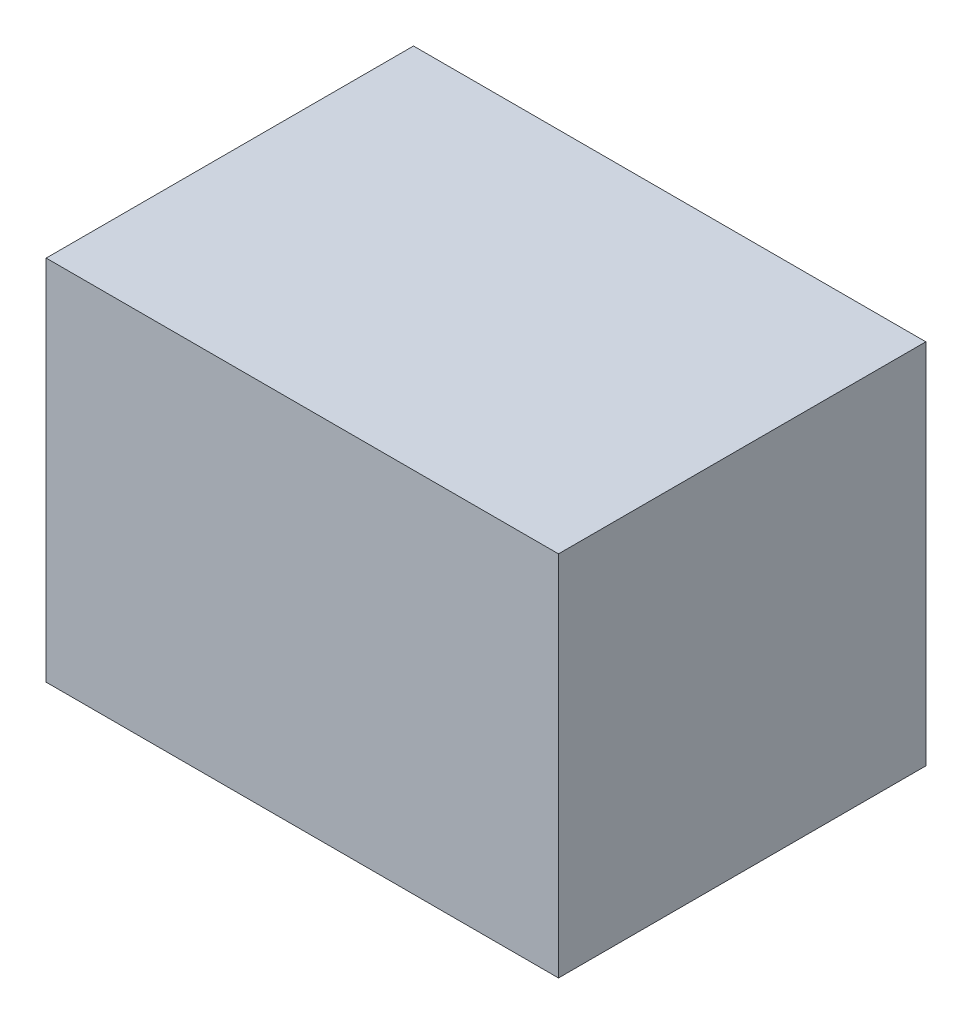
from build123d import *

# Parameters (mm, degrees)
SKETCH1_W           = 53
SKETCH1_H           = 38
BOSS_EXTRUDE1_DEPTH = 38


with BuildPart() as part:
    # Sketch1 → Boss-Extrude1 (new body)
    with BuildSketch(Plane.XY):
        with Locations((26.5, 19)):
            Rectangle(SKETCH1_W, SKETCH1_H)
    extrude(amount=BOSS_EXTRUDE1_DEPTH)


solid = part.part
